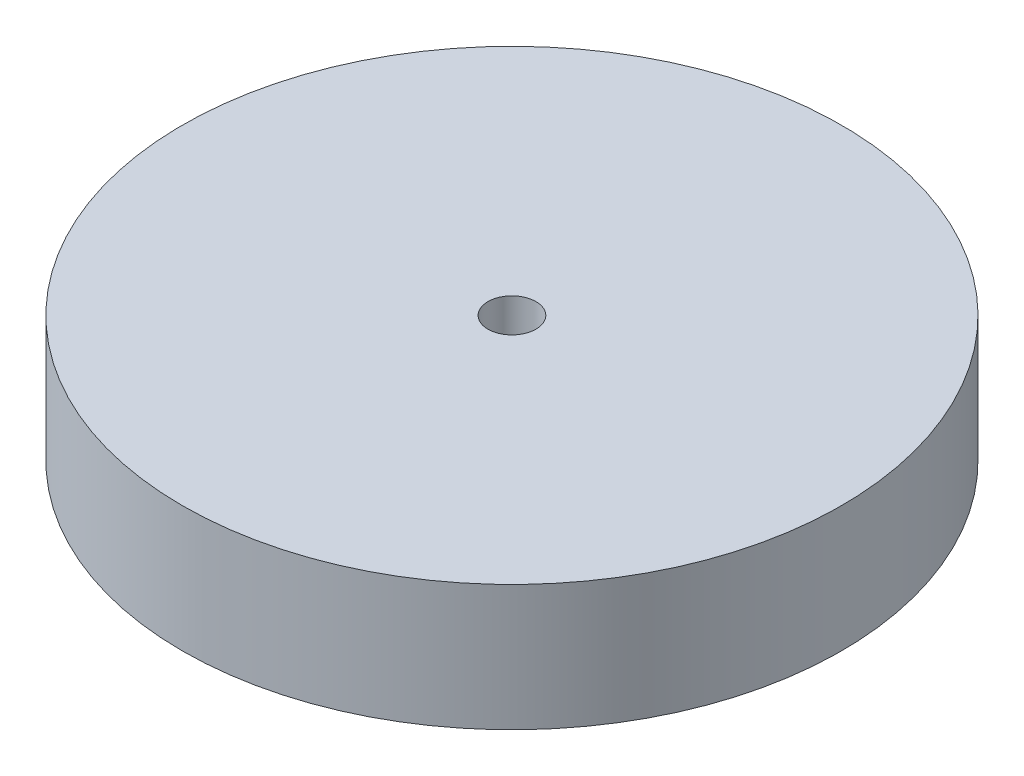
from build123d import *

# Parameters (mm, degrees)
SKETCH1_R           = 55
SKETCH1_R_2         = 4
BOSS_EXTRUDE1_DEPTH = 21


with BuildPart() as part:
    # Sketch1 → Boss-Extrude1 (new body)
    with BuildSketch(Plane(origin=(0, 0, 0), x_dir=(1, 0, 0), z_dir=(0, 1, 0))):
        Circle(SKETCH1_R)
        Circle(SKETCH1_R_2, mode=Mode.SUBTRACT)
    extrude(amount=BOSS_EXTRUDE1_DEPTH)


solid = part.part
